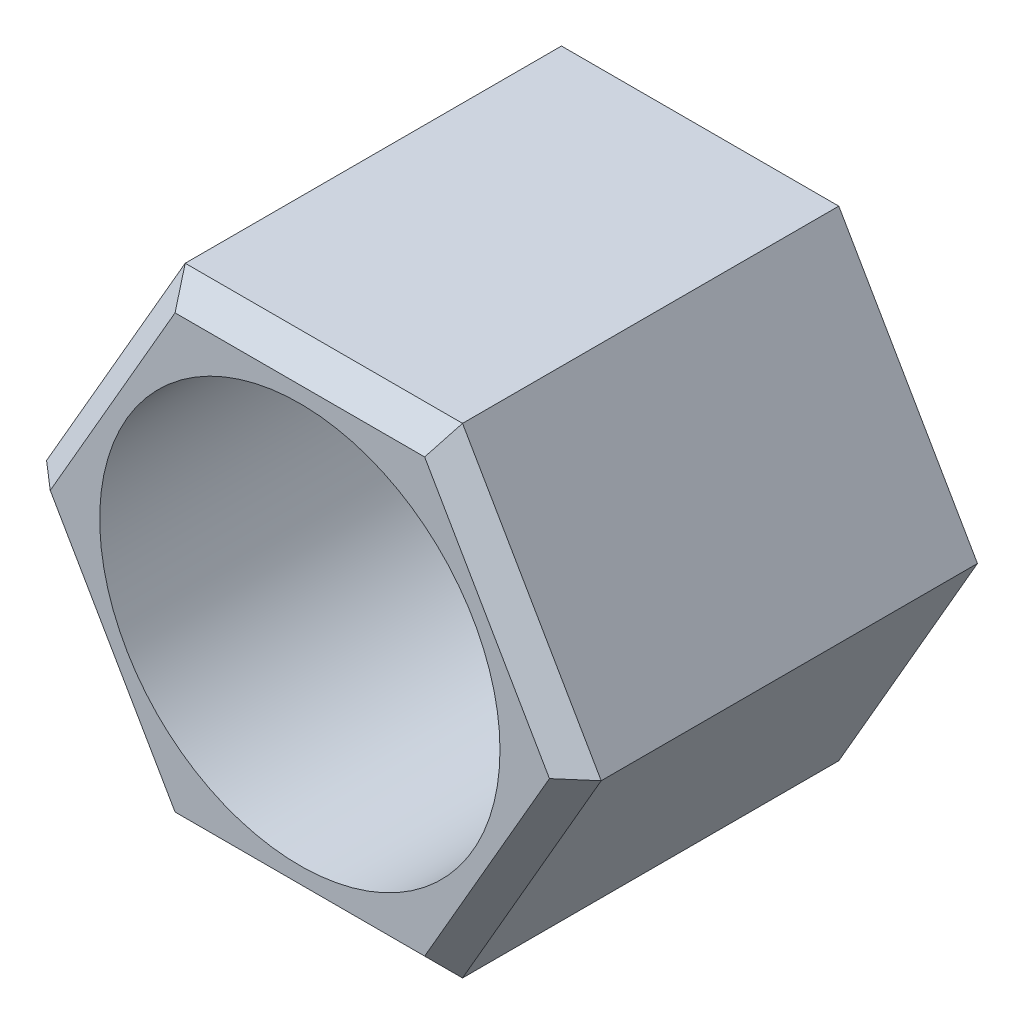
from build123d import *

# Parameters (mm, degrees)
EXTRUDE1_DEPTH     = 12.7
SKETCH4_R          = 6.35
CUT_EXTRUDE1_DEPTH = 13.7
CHAMFER2_SIZE      = 0.762


with BuildPart() as part:
    # Sketch2 → Extrude1 (new body)
    with BuildSketch(Plane.XY):
        Polygon((8.798818102, 0), (4.399409051, 7.62), (-4.399409051, 7.62), (-8.798818102, 0), (-4.399409051, -7.62), (4.399409051, -7.62), align=None)
    extrude(amount=EXTRUDE1_DEPTH)

    # Sketch4 → Cut-Extrude1 (cut, through all)
    with BuildSketch(Plane.XY.offset(12.7)):
        Circle(SKETCH4_R)
    extrude(amount=-CUT_EXTRUDE1_DEPTH, mode=Mode.SUBTRACT)

    # Chamfer2
    chamfer2_edges = [part.edges().sort_by_distance(p)[0] for p in [
        (0, 7.62, 12.7),
        (-6.599113577, 3.81, 12.7),
        (-6.599113577, -3.81, 12.7),
        (0, -7.62, 12.7),
        (6.599113577, -3.81, 12.7),
        (6.599113577, 3.81, 12.7),
    ]]
    chamfer(chamfer2_edges, length=CHAMFER2_SIZE)


solid = part.part
